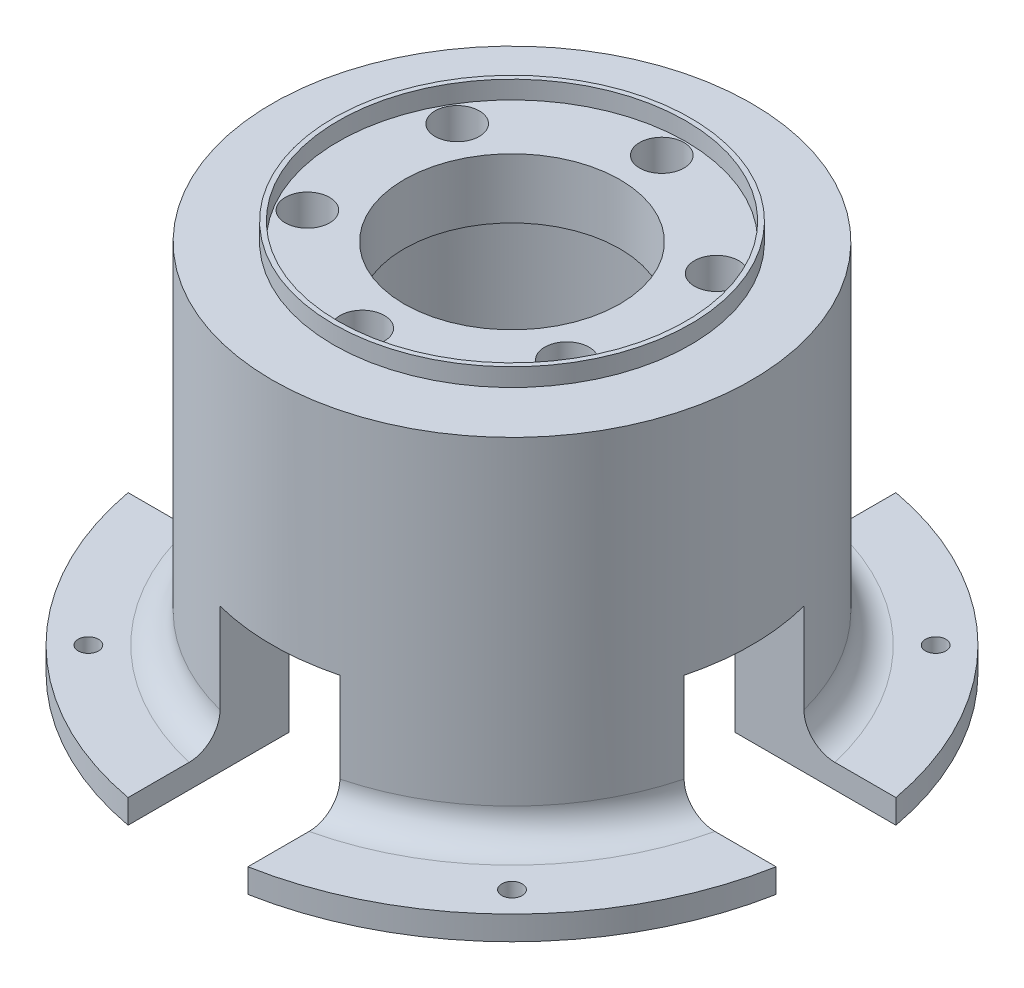
from build123d import *

# Parameters (mm, degrees)
SKETCH_1_R               = 55
EXTRUDE_1_DEPTH          = 10
SKETCH_2_R               = 40
SKETCH_2_R_2             = 29
EXTRUDE_2_DEPTH          = 58.3
SKETCH_3_R               = 29.8
SKETCH_3_R_2             = 29
EXTRUDE_3_DEPTH          = 3
SKETCH_6_W               = 20
SKETCH_6_H               = 20
CUT_EXTRUDE_3_DEPTH      = 55.5
PATTERN_CIRCULAR_1_COUNT = 4
SKETCH_9_R               = 1.7
CUT_EXTRUDE_6_DEPTH      = 10
SKETCH_10_R              = 29
SKETCH_10_R_2            = 18
EXTRUDE_4_DEPTH          = 10
SKETCH_11_R              = 1.7
CUT_EXTRUDE_7_DEPTH      = 10
SKETCH_12_R              = 29
CUT_EXTRUDE_8_DEPTH      = 10
SKETCH_13_W              = 160.430825531
SKETCH_13_H              = 122.201891545
CUT_EXTRUDE_9_DEPTH      = 6
SKETCH_14_R              = 3.7
CUT_EXTRUDE_10_DEPTH     = 5.5
CUT_EXTRUDE_11_DEPTH     = 5.5
FILLET_1_R               = 5


with BuildPart() as part:
    # 草图1 → 凸台-拉伸1 (new body)
    with BuildSketch(Plane(origin=(0, 0, 0), x_dir=(1, 0, 0), z_dir=(0, 1, 0))):
        Circle(SKETCH_1_R)
    extrude(amount=EXTRUDE_1_DEPTH)

    # 草图2 → 凸台-拉伸2 (add)
    with BuildSketch(Plane(origin=(0, 10, 0), x_dir=(1, 0, 0), z_dir=(0, 1, 0))):
        Circle(SKETCH_2_R)
        Circle(SKETCH_2_R_2, mode=Mode.SUBTRACT)
    extrude(amount=EXTRUDE_2_DEPTH)

    # 草图3 → 凸台-拉伸3 (add)
    with BuildSketch(Plane(origin=(0, 68.3, 0), x_dir=(1, 0, 0), z_dir=(0, 1, 0))):
        Circle(SKETCH_3_R)
        Circle(SKETCH_3_R_2, mode=Mode.SUBTRACT)
    extrude(amount=EXTRUDE_3_DEPTH)

    # 草图6 → 切除-拉伸3 (cut, symmetric)
    with BuildSketch(Plane(origin=(0, 0, 0), x_dir=(0, 0, -1), z_dir=(1, 0, 0))):
        with Locations((0, 20)):
            Rectangle(SKETCH_6_W, SKETCH_6_H)
    cut_extrude_3 = extrude(amount=CUT_EXTRUDE_3_DEPTH, both=True, mode=Mode.SUBTRACT)

    # 阵列(圆周)1: 切除-拉伸3 ×4 about axis
    pattern_circular_1_axis = Axis((0, 68.3, 0), (0, -1, 0))
    for i in range(1, PATTERN_CIRCULAR_1_COUNT):
        add(cut_extrude_3.rotate(pattern_circular_1_axis, i * 360 / PATTERN_CIRCULAR_1_COUNT), mode=Mode.SUBTRACT)

    # 草图9 → 切除-拉伸6 (cut)
    with BuildSketch(Plane.XZ):
        with Locations((50, 0)):
            Circle(SKETCH_9_R)
        with Locations((35.355339059, -35.355339059)):
            Circle(SKETCH_9_R)
        with Locations((0, -50)):
            Circle(SKETCH_9_R)
        with Locations((-35.355339059, -35.355339059)):
            Circle(SKETCH_9_R)
        with Locations((-50, 0)):
            Circle(SKETCH_9_R)
        with Locations((-35.355339059, 35.355339059)):
            Circle(SKETCH_9_R)
        with Locations((0, 50)):
            Circle(SKETCH_9_R)
        with Locations((35.355339059, 35.355339059)):
            Circle(SKETCH_9_R)
    extrude(amount=-CUT_EXTRUDE_6_DEPTH, mode=Mode.SUBTRACT)

    # 草图10 → 凸台-拉伸4 (add)
    with BuildSketch(Plane(origin=(0, 68.3, 0), x_dir=(1, 0, 0), z_dir=(0, 1, 0))):
        Circle(SKETCH_10_R)
        Circle(SKETCH_10_R_2, mode=Mode.SUBTRACT)
    extrude(amount=-EXTRUDE_4_DEPTH)

    # 草图11 → 切除-拉伸7 (cut)
    with BuildSketch(Plane(origin=(0, 68.3, 0), x_dir=(1, 0, 0), z_dir=(0, 1, 0))):
        with Locations((0, -25)):
            Circle(SKETCH_11_R)
        with Locations((-21.650635095, -12.5)):
            Circle(SKETCH_11_R)
        with Locations((-21.650635095, 12.5)):
            Circle(SKETCH_11_R)
        with Locations((0, 25)):
            Circle(SKETCH_11_R)
        with Locations((21.650635095, 12.5)):
            Circle(SKETCH_11_R)
        with Locations((21.650635095, -12.5)):
            Circle(SKETCH_11_R)
    extrude(amount=-CUT_EXTRUDE_7_DEPTH, mode=Mode.SUBTRACT)

    # 草图12 → 切除-拉伸8 (cut)
    with BuildSketch(Plane(origin=(0, 10, 0), x_dir=(1, 0, 0), z_dir=(0, 1, 0))):
        Circle(SKETCH_12_R)
    extrude(amount=-CUT_EXTRUDE_8_DEPTH, mode=Mode.SUBTRACT)

    # 草图13 → 切除-拉伸9 (cut)
    with BuildSketch(Plane.XZ):
        with Locations((1.79708664, -1.633715128)):
            Rectangle(SKETCH_13_W, SKETCH_13_H)
    extrude(amount=-CUT_EXTRUDE_9_DEPTH, mode=Mode.SUBTRACT)

    # 草图14 → 切除-拉伸10 (cut)
    with BuildSketch(Plane(origin=(0, 68.3, 0), x_dir=(1, 0, 0), z_dir=(0, 1, 0))):
        with Locations((21.650635095, 12.5)):
            Circle(SKETCH_14_R)
        with Locations((21.650635095, -12.5)):
            Circle(SKETCH_14_R)
        with Locations((0, -25)):
            Circle(SKETCH_14_R)
        with Locations((-21.650635095, -12.5)):
            Circle(SKETCH_14_R)
        with Locations((-21.650635095, 12.5)):
            Circle(SKETCH_14_R)
        with Locations((0, 25)):
            Circle(SKETCH_14_R)
    extrude(amount=-CUT_EXTRUDE_10_DEPTH, mode=Mode.SUBTRACT)

    # 草图15 → 切除-拉伸11 (cut)
    with BuildSketch(Plane(origin=(0, 10, 0), x_dir=(1, 0, 0), z_dir=(0, 1, 0))):
        Polygon((10, 10), (59.580067328, 10), (59.580067328, -10), (10, -10), (10, -56.748157484), (-10, -56.748157484), (-10, -10), (-60.120716696, -10), (-60.120716696, 10), (-10, 10), (-10, 63.130274599), (10, 63.130274599), align=None)
    extrude(amount=-CUT_EXTRUDE_11_DEPTH, mode=Mode.SUBTRACT)

    # 圆角1
    fillet_1_edges = [part.edges().sort_by_distance(p)[0] for p in [
        (28.284271247, 10, -28.284271247),
        (-28.284271247, 10, 28.284271247),
        (-28.284271247, 10, -28.284271247),
        (28.284271247, 10, 28.284271247),
    ]]
    fillet(fillet_1_edges, radius=FILLET_1_R)


solid = part.part
